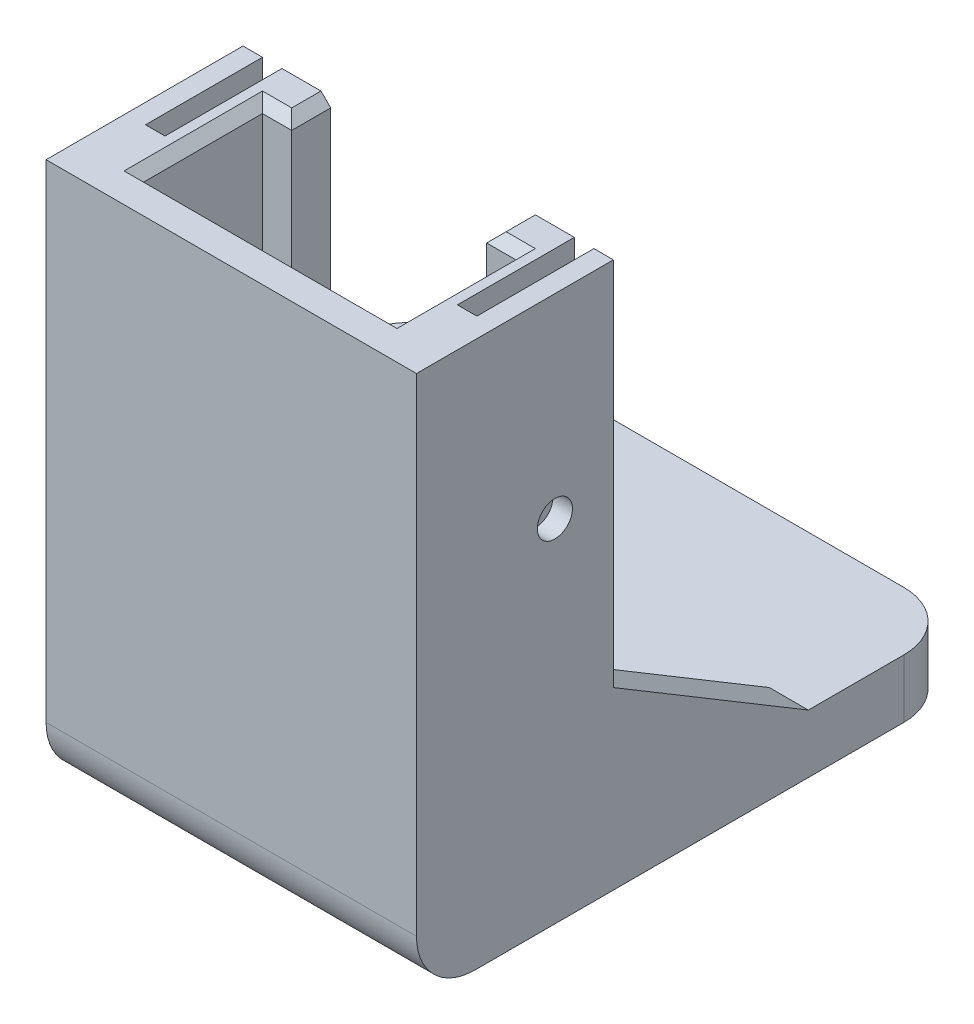
from build123d import *

# Parameters (mm, degrees)
EXTRUDE_1_DEPTH           = 25
SKETCH_2_W                = 19
SKETCH_2_H                = 28
SKETCH_2_R                = 1.5
EXTRUDE_2_DEPTH           = 3
SKETCH_3_W                = 1
SKETCH_3_H                = 6
CUT_EXTRUDE_1_DEPTH       = 15
SKETCH_4_R                = 0.9
CUT_EXTRUDE_2_DEPTH       = 19
FILLET_1_R                = 3
EXTRUDE_3_DEPTH           = 2
EXTRUDE_4_DEPTH           = 5
FILLET_2_R                = 3
CHAMFER_1_SIZE            = 0.5
EXTRUDE_5_DEPTH           = 3
HOLE_WIZARD_3_0_3_1_D     = 3
HOLE_WIZARD_3_0_3_1_DEPTH = 3


with BuildPart() as part:
    # 草图1 → 凸台-拉伸1 (new body)
    with BuildSketch(Plane(origin=(0, 0, 0), x_dir=(1, 0, 0), z_dir=(0, 1, 0))):
        Polygon((-9.5, 10.1), (-9.5, 0), (9.5, 0), (9.5, 10.1), (5, 10.1), (5, 8.1), (6.5, 8.1), (6.5, 2), (-6.5, 2), (-6.5, 8.1), (-5, 8.1), (-5, 10.1), align=None)
    extrude(amount=EXTRUDE_1_DEPTH)

    # 草图2 → 凸台-拉伸2 (add)
    with BuildSketch(Plane.XZ):
        with Locations((0, -14)):
            Rectangle(SKETCH_2_W, SKETCH_2_H)
        with Locations((4, -25)):
            Circle(SKETCH_2_R, mode=Mode.SUBTRACT)
        with Locations((-4, -25)):
            Circle(SKETCH_2_R, mode=Mode.SUBTRACT)
    extrude(amount=EXTRUDE_2_DEPTH)

    # 草图3 → 切除-拉伸1 (cut)
    with BuildSketch(Plane(origin=(0, 25, 0), x_dir=(1, 0, 0), z_dir=(0, 1, 0))):
        with Locations((-8, 7.1)):
            Rectangle(SKETCH_3_W, SKETCH_3_H)
        with Locations((8, 7.1)):
            Rectangle(SKETCH_3_W, SKETCH_3_H)
    extrude(amount=-CUT_EXTRUDE_1_DEPTH, mode=Mode.SUBTRACT)

    # 草图4 → 切除-拉伸2 (cut)
    with BuildSketch(Plane.ZY.offset(9.5)):
        with Locations((-7.1, 15)):
            Circle(SKETCH_4_R)
    extrude(amount=-CUT_EXTRUDE_2_DEPTH, mode=Mode.SUBTRACT)

    # 圆角1
    fillet_1_edges = [part.edges().sort_by_distance(p)[0] for p in [
        (9.5, -1.5, -28),
        (-9.5, -1.5, -28),
    ]]
    fillet(fillet_1_edges, radius=FILLET_1_R)

    # 草图5 → 凸台-拉伸3 (add)
    with BuildSketch(Plane.ZY.offset(9.5)):
        Polygon((-10.1, 0), (-10.1, 6), (-20.1, 0), align=None)
    extrude_3 = extrude(amount=-EXTRUDE_3_DEPTH)

    # 镜向1: 凸台-拉伸3 across plane
    add(extrude_3.mirror(Plane(origin=(0, 0, 0), x_dir=(0, 0, 1), z_dir=(1, 0, 0))))

    # 草图6 → 凸台-拉伸4 (add)
    with BuildSketch(Plane(origin=(0, 0, 0), x_dir=(1, 0, 0), z_dir=(0, 1, 0))):
        Polygon((-6.5, 2), (6.5, 2), (6.5, 8.1), (5, 8.1), (5, 10.1), (-5, 10.1), (-5, 8.1), (-6.5, 8.1), align=None)
    extrude(amount=EXTRUDE_4_DEPTH)

    # 圆角2
    fillet_2_edges = [part.edges().sort_by_distance(p)[0] for p in [
        (0, -3, 0),
    ]]
    fillet(fillet_2_edges, radius=FILLET_2_R)

    # 倒角1
    chamfer_1_edges = [part.edges().sort_by_distance(p)[0] for p in [
        (5, 25, -9.1),
        (5.75, 25, -8.1),
        (6.5, 25, -5.05),
        (0, 25, -2),
        (-6.5, 25, -5.05),
        (-5.75, 25, -8.1),
        (-5, 25, -9.1),
    ]]
    chamfer(chamfer_1_edges, length=CHAMFER_1_SIZE)

    # 草图7 → 凸台-拉伸5 (add)
    with BuildSketch(Plane(origin=(0, 0, 0), x_dir=(1, 0, 0), z_dir=(0, 1, 0))):
        with BuildLine():
            Line((6.5, 28), (-15.797958971, 28))
            ThreePointArc((-15.797958971, 28), (-17.919279315, 27.121320344), (-18.797958971, 25))
            Line((-18.797958971, 25), (-18.797958971, 23.1))
            ThreePointArc((-18.797958971, 23.1), (-17.919279315, 20.978679656), (-15.797958971, 20.1))
            Line((-15.797958971, 20.1), (6.5, 20.1))
            Line((6.5, 20.1), (6.5, 28))
        make_face()
    extrude(amount=-EXTRUDE_5_DEPTH)

    # Ø3.0 (3) 直径孔1
    with Locations(Plane(origin=(0, 0, 0), x_dir=(1, 0, 0), z_dir=(0, 1, 0))):
        with Locations((-5.797958971, 23), (-13.797958971, 23)):
            Hole(HOLE_WIZARD_3_0_3_1_D / 2, depth=HOLE_WIZARD_3_0_3_1_DEPTH)


solid = part.part
